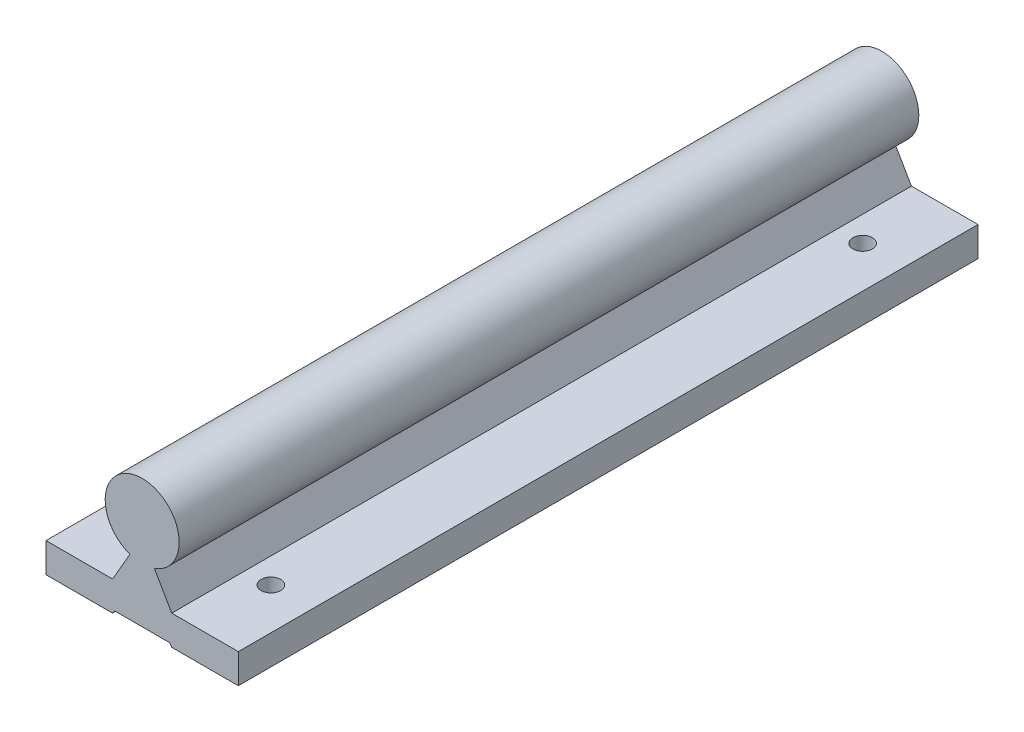
from build123d import *

# Parameters (mm, degrees)
SKETCH_2_R                  = 12.5
EXTRUDE_2_DEPTH             = 250
EXTRUDE_3_DEPTH             = 250
SKETCH_7_R                  = 3.3
CUT_EXTRUDE_1_DEPTH         = 255.449269797
HOLE_WIZARD_M51_D           = 5.3
HOLE_WIZARD_M51_DEPTH       = 18
HOLE_WIZARD_M51_CBORE_D     = 10
HOLE_WIZARD_M51_CBORE_DEPTH = 5
HOLE_WIZARD_M51_TIP         = 1.59228064


with BuildPart() as part:
    # Эскиз2 → Бобышка-Вытянуть2 (new body)
    with BuildSketch(Plane.XY):
        Circle(SKETCH_2_R)
    extrude(amount=EXTRUDE_2_DEPTH)

    # Эскиз2<4> → Бобышка-Вытянуть3 (add)
    with BuildSketch(Plane.XY):
        with BuildLine():
            Line((10, -21.97), (4.127670885, -11.798827614))
            ThreePointArc((4.127670885, -11.798827614), (0, -12.5), (-4.127670885, -11.798827614))
            Line((-4.127670885, -11.798827614), (-10, -21.97))
            Line((-10, -21.97), (-32.5, -21.97))
            Line((-32.5, -21.97), (-32.5, -31.97))
            Line((-32.5, -31.97), (-10, -31.97))
            Line((-10, -31.97), (-9.299792462, -30.97))
            Line((-9.299792462, -30.97), (9.299792462, -30.97))
            Line((9.299792462, -30.97), (10, -31.97))
            Line((10, -31.97), (32.5, -31.97))
            Line((32.5, -31.97), (32.5, -21.97))
            Line((32.5, -21.97), (10, -21.97))
        make_face()
    extrude(amount=EXTRUDE_3_DEPTH)

    # Эскиз7 → Вырез-Вытянуть1 (cut, through all)
    with BuildSketch(Plane(origin=(0, -21.97, 0), x_dir=(1, 0, 0), z_dir=(0, 1, 0))):
        with Locations((-18.5, -225)):
            Circle(SKETCH_7_R)
        with Locations((18.5, -225)):
            Circle(SKETCH_7_R)
        with Locations((18.5, -25)):
            Circle(SKETCH_7_R)
        with Locations((-18.5, -25)):
            Circle(SKETCH_7_R)
    extrude(amount=-CUT_EXTRUDE_1_DEPTH, mode=Mode.SUBTRACT)

    # Цековка для винта с внутренним шестигранником M51
    with Locations(Plane(origin=(0, -30.97, 0), x_dir=(-1, 0, 0), z_dir=(0, -1, 0))):
        with Locations((0, -25), (0, -225)):
            CounterBoreHole(HOLE_WIZARD_M51_D / 2, HOLE_WIZARD_M51_CBORE_D / 2, HOLE_WIZARD_M51_CBORE_DEPTH, depth=HOLE_WIZARD_M51_DEPTH)
            with Locations((0, 0, -(HOLE_WIZARD_M51_DEPTH + HOLE_WIZARD_M51_TIP / 2))):  # 118° drill point
                Cone(0, HOLE_WIZARD_M51_D / 2, HOLE_WIZARD_M51_TIP, mode=Mode.SUBTRACT)


solid = part.part
